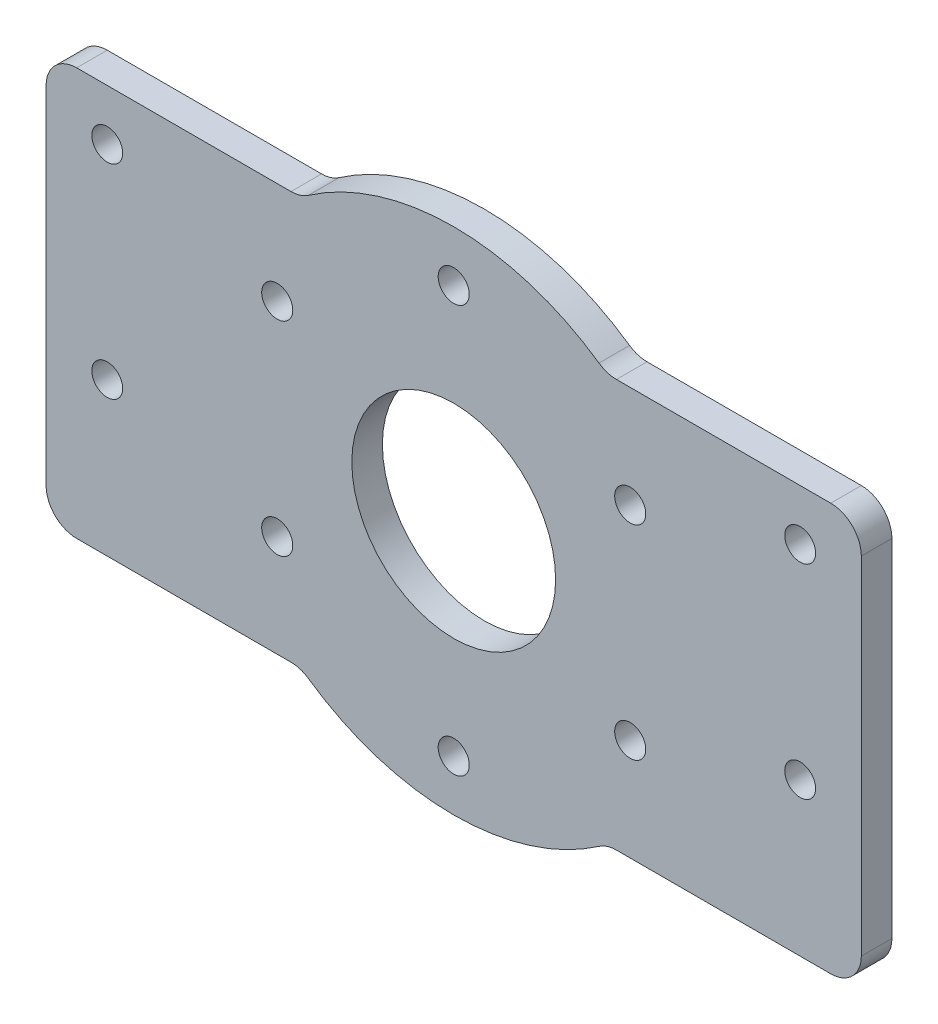
from build123d import *

# Parameters (mm, degrees)
SKETCH_1_R          = 25
SKETCH_1_R_2        = 1.525
SKETCH_1_R_3        = 10
EXTRUDE_1_DEPTH     = 3
EXTRUDE_2_DEPTH     = 3
FILLET_1_R          = 3
SKETCH_4_R          = 1.515
CUT_EXTRUDE_1_DEPTH = 10


with BuildPart() as part:
    # 草图1 → 凸台-拉伸1 (new body)
    with BuildSketch(Plane.XY):
        Circle(SKETCH_1_R)
        with Locations((0, 20)):
            Circle(SKETCH_1_R_2, mode=Mode.SUBTRACT)
        with Locations((17.320508076, 10)):
            Circle(SKETCH_1_R_2, mode=Mode.SUBTRACT)
        with Locations((17.320508076, -10)):
            Circle(SKETCH_1_R_2, mode=Mode.SUBTRACT)
        with Locations((0, -20)):
            Circle(SKETCH_1_R_2, mode=Mode.SUBTRACT)
        Circle(SKETCH_1_R_3, mode=Mode.SUBTRACT)
        with Locations((-17.320508076, -10)):
            Circle(SKETCH_1_R_2, mode=Mode.SUBTRACT)
        with Locations((-17.320508076, 10)):
            Circle(SKETCH_1_R_2, mode=Mode.SUBTRACT)
    extrude(amount=EXTRUDE_1_DEPTH)

    # 草图3 → 凸台-拉伸2 (add)
    with BuildSketch(Plane.XY.offset(3)):
        with BuildLine():
            Line((15, 20), (40, 20))
            Line((40, 20), (40, -20))
            Line((40, -20), (15, -20))
            ThreePointArc((15, -20), (25, 0), (15, 20))
        make_face()
        with BuildLine():
            Line((-40, -20), (-15, -20))
            ThreePointArc((-15, -20), (-25, 0), (-15, 20))
            Line((-15, 20), (-40, 20))
            Line((-40, 20), (-40, -20))
        make_face()
    extrude(amount=-EXTRUDE_2_DEPTH)

    # 圆角1
    fillet_1_edges = [part.edges().sort_by_distance(p)[0] for p in [
        (40, 20, 1.5),
        (40, -20, 1.5),
        (15, -20, 1.5),
        (15, 20, 1.5),
        (-40, -20, 1.5),
        (-40, 20, 1.5),
        (-15, 20, 1.5),
        (-15, -20, 1.5),
    ]]
    fillet(fillet_1_edges, radius=FILLET_1_R)

    # 草图4 → 切除-拉伸1 (cut)
    with BuildSketch(Plane.XY.offset(3)):
        with Locations((-34, 15)):
            Circle(SKETCH_4_R)
        with Locations((-34, -5)):
            Circle(SKETCH_4_R)
        with Locations((34, -5)):
            Circle(SKETCH_4_R)
        with Locations((34, 15)):
            Circle(SKETCH_4_R)
    extrude(amount=-CUT_EXTRUDE_1_DEPTH, mode=Mode.SUBTRACT)


solid = part.part
